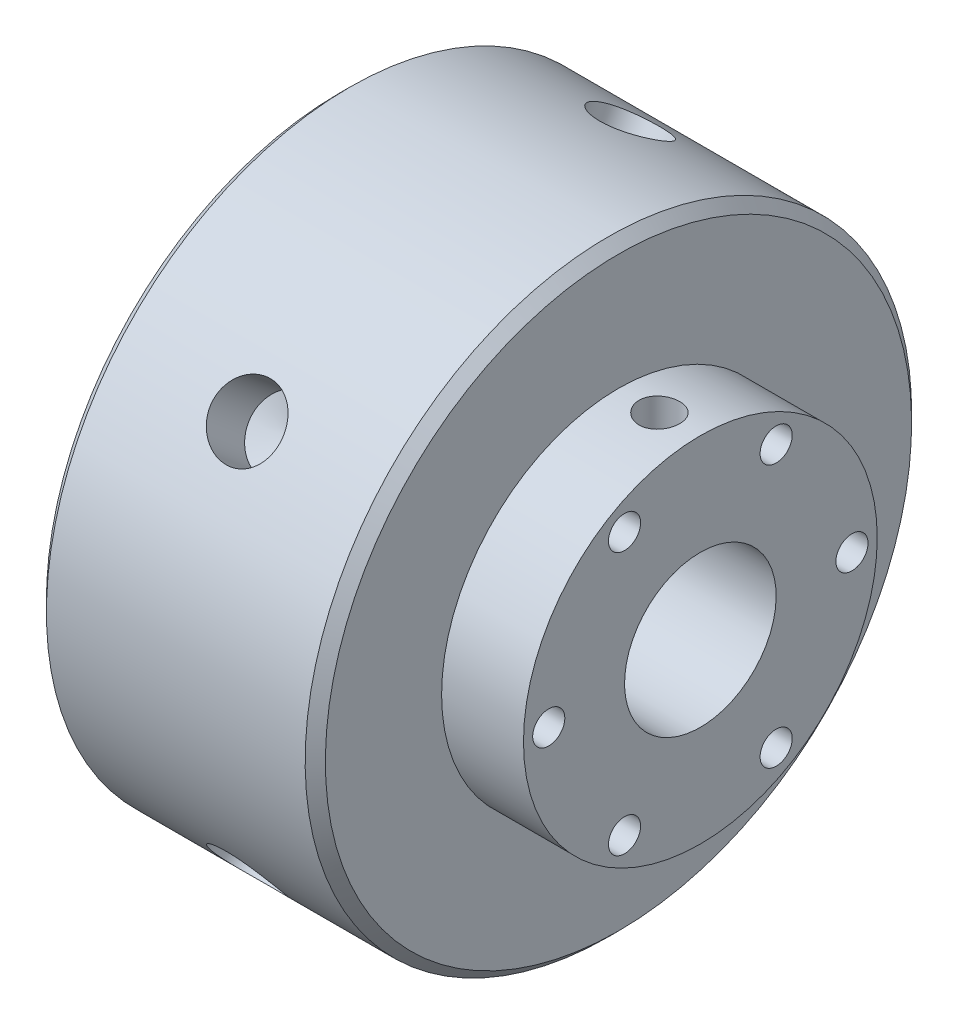
from build123d import *

# Parameters (mm, degrees)
SKETCH2_R                = 9.525
BORE_DEPTH               = 78.443346235
FACE_MOUNT_SCREWS_D      = 4.0386
SKETCH5_W                = 2.5527
SKETCH5_H                = 38.1
SET_SCREWS_AT_2_COUNT    = 2
SET_SCREWS_AT_2_PITCH    = 45.339
CHAMFER1_SIZE            = 1.27
SKETCH15_R               = 2
BOSS_EXTRUDE1_DEPTH      = 1
BOSS_EXTRUDE1_DEPTH_BACK = 20.32
SKETCH16_R               = 3.5
BOSS_EXTRUDE2_DEPTH      = 4
CHAMFER2_SIZE            = 0.381
CUT_EXTRUDE2_DEPTH       = 2
LPATTERN2_COUNT          = 2
LPATTERN2_PITCH          = 9.252966
LPATTERN2_2_COUNT        = 2
LPATTERN2_2_PITCH        = 9.252966
SKETCH18_R               = 22.225
SKETCH18_R_2             = 9.525
CUT_EXTRUDE3_DEPTH       = 0.0635
CIRPATTERN1_COUNT        = 4
CIRPATTERN1_ANGLE        = 240


with BuildPart() as part:
    # Sketch1 → Hub (revolve)
    with BuildSketch(Plane.XY, mode=Mode.PRIVATE) as hub_sk:
        Polygon((-17.526, 38.1), (17.526, 38.1), (17.526, 22.225), (27.813, 22.225), (27.813, 0), (-27.813, 0), (-27.813, 22.225), (-17.526, 22.225), align=None)
    revolve(hub_sk.sketch.rotate(Axis((-27.813, 0, 0), (1, 0, 0)), 180), axis=Axis((-27.813, 0, 0), (1, 0, 0)))

    # Sketch2 → Bore (cut, through all)
    with BuildSketch(Plane(origin=(27.813, 0, 0), x_dir=(0, 0, -1), z_dir=(1, 0, 0))):
        with Locations(Location((0, 0, 0), (0, 0, 90))):
            Circle(SKETCH2_R)
    extrude(amount=-BORE_DEPTH, mode=Mode.SUBTRACT)

    # Face Mount Screws (through all)
    with Locations(Plane(origin=(27.813, 0, 0), x_dir=(0, 0, -1), z_dir=(1, 0, 0))):
        with Locations((-19.05, 0), (9.525, 16.497783942), (9.525, -16.497783942), (-9.525, -16.497783942), (19.05, 0), (-9.525, 16.497783942)):
            Hole(FACE_MOUNT_SCREWS_D / 2)

    # Sketch5 → Set Screws (revolve, cut)
    with BuildSketch(Plane(origin=(-22.6695, 0, 0), x_dir=(0, 0, -1), z_dir=(1, 0, 0))):
        with Locations((1.27635, 19.05)):
            Rectangle(SKETCH5_W, SKETCH5_H)
    set_screws = revolve(axis=Axis((-22.6695, -6.35, 0), (0, 1, 0)), mode=Mode.SUBTRACT)

    # Set Screws at 2: Set Screws ×2
    with Locations(*[(i * SET_SCREWS_AT_2_PITCH, 0, 0) for i in range(1, SET_SCREWS_AT_2_COUNT)]):
        add(set_screws, mode=Mode.SUBTRACT)

    # Chamfer1
    chamfer1_edges = [part.edges().sort_by_distance(p)[0] for p in [
        (-17.526, 38.1, 0),
        (17.526, 38.1, 0),
    ]]
    chamfer(chamfer1_edges, length=CHAMFER1_SIZE)

    # Sketch12 → Cut-Revolve1 (revolve, cut)
    with BuildSketch(Plane.XY.offset(-33.02), mode=Mode.PRIVATE) as cut_revolve1_sk:
        Polygon((-4, 38.1), (-4, 7.62), (-2.25, 7.62), (-2.25, -38.1), (0, -38.1), (0, 38.1), align=None)
    revolve(cut_revolve1_sk.sketch.rotate(Axis((0, -38.1, -33.02), (0, 1, 0)), 180), axis=Axis((0, -38.1, -33.02), (0, 1, 0)), mode=Mode.SUBTRACT)

    # Sketch14 → Cut-Revolve2 (revolve, cut)
    with BuildSketch(Plane.XY.offset(-33.02)):
        Polygon((-9.253, -38.1), (-13.253, -38.1), (-13.253, -7.62), (-11.503, -7.62), (-11.503, 38.1), (-9.253, 38.1), align=None)
    cut_revolve2 = revolve(axis=Axis((-9.253, 38.1, -33.02), (0, -1, 0)), mode=Mode.SUBTRACT)

    # Mirror2: Cut-Revolve2 across plane
    add(cut_revolve2.mirror(Plane(origin=(0, 0, 0), x_dir=(0, 0, 1), z_dir=(1, 0, 0))), mode=Mode.SUBTRACT)

    # Sketch18 → Cut-Extrude3 (cut, symmetric)
    with BuildSketch(Plane(origin=(0, 0, 0), x_dir=(0, 0, -1), z_dir=(1, 0, 0))):
        with Locations(Location((0, 0, 0), (0, 0, 270))):
            Circle(SKETCH18_R)
        with Locations(Location((0, 0, 0), (0, 0, 90))):
            Circle(SKETCH18_R_2, mode=Mode.SUBTRACT)
    extrude(amount=CUT_EXTRUDE3_DEPTH, both=True, mode=Mode.SUBTRACT)

    # Sketch19 → R _0.339_ Diameter Hole1 (revolve, cut)
    with BuildSketch(Plane(origin=(0, -32.995567884, -19.05), x_dir=(0, 0.499999999999998, -0.8660254037844399), z_dir=(1, 0, 0))):
        Polygon((0, 0), (0, 8.944516153), (4.318, 6.35), (4.318, 0), align=None)
    r_0_339_diameter_hole1 = revolve(axis=Axis((0, -38.494829198, -22.225), (0, 0.8660254037844398, 0.49999999999999795)), mode=Mode.SUBTRACT)

    # CirPattern1: R _0.339_ Diameter Hole1 ×4 about axis
    cirpattern1_axis = Axis((-27.813, 0, 0), (-1, 0, 0))
    for i in range(1, CIRPATTERN1_COUNT):
        add(r_0_339_diameter_hole1.rotate(cirpattern1_axis, i * CIRPATTERN1_ANGLE / (CIRPATTERN1_COUNT - 1)), mode=Mode.SUBTRACT)


with BuildPart() as body_2:
    # Sketch15 → Boss-Extrude1 (new, two sides)
    with BuildSketch(Plane(origin=(0, 7.62, 0), x_dir=(1, 0, 0), z_dir=(0, 1, 0))) as boss_extrude1_sk:
        with Locations(Location((0, 33.02, 0), (0, 0, 180))):
            Circle(SKETCH15_R)
    extrude(amount=BOSS_EXTRUDE1_DEPTH)
    extrude(boss_extrude1_sk.sketch, amount=-BOSS_EXTRUDE1_DEPTH_BACK)

    # Sketch16 → Boss-Extrude2 (add)
    with BuildSketch(Plane(origin=(0, 8.62, 0), x_dir=(1, 0, 0), z_dir=(0, 1, 0))):
        with Locations(Location((0, 33.02, 0), (0, 0, 180))):
            Circle(SKETCH16_R)
    extrude(amount=BOSS_EXTRUDE2_DEPTH)

    # Chamfer2
    chamfer2_edges = [body_2.edges().sort_by_distance(p)[0] for p in [
        (2, -12.7, -33.02),
        (3.5, 12.62, -33.02),
    ]]
    chamfer(chamfer2_edges, length=CHAMFER2_SIZE)

    # Sketch17 → Cut-Extrude2 (cut)
    with BuildSketch(Plane(origin=(0, 12.62, 0), x_dir=(1, 0, 0), z_dir=(0, 1, 0))):
        Polygon((0.721687836, 34.27), (-0.721687836, 34.27), (-1.443375673, 33.02), (-0.721687836, 31.77), (0.721687836, 31.77), (1.443375673, 33.02), align=None)
    extrude(amount=-CUT_EXTRUDE2_DEPTH, mode=Mode.SUBTRACT)


with BuildPart() as lpattern2_1:
    # LPattern2: pattern copy
    add(body_2.part.moved(Location(Vector(1, 0, 0) * (1 * LPATTERN2_PITCH))))


with BuildPart() as lpattern2_2_1:
    # LPattern2 2: pattern copy
    add(body_2.part.moved(Location(Vector(-1, 0, 0) * (1 * LPATTERN2_2_PITCH))))


with BuildPart() as body_5:
    # Mirror4: mirrored copy
    add(lpattern2_1.part.mirror(Plane.ZX))


with BuildPart() as body_6:
    # Mirror4 2: mirrored copy
    add(lpattern2_2_1.part.mirror(Plane.ZX))


solid = Compound([part.part, body_2.part, body_5.part, body_6.part])
